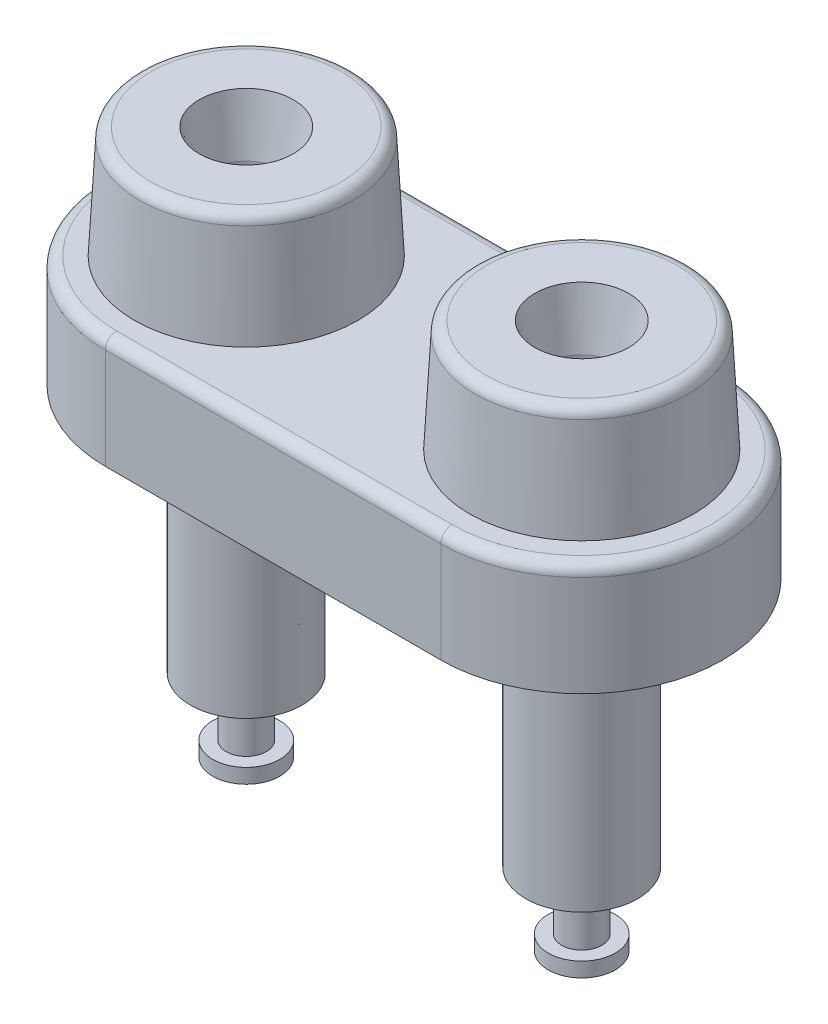
from build123d import *

# Parameters (mm, degrees)
BOSS_EXTRUDE1_DEPTH = 6.35
SKETCH2_R           = 6.35
BOSS_EXTRUDE2_DEPTH = 6.35
BOSS_EXTRUDE2_TAPER = 3
SKETCH3_R           = 4.699
BOSS_EXTRUDE3_DEPTH = 0.889
LPATTERN1_COUNT     = 2
LPATTERN1_PITCH     = 19.05
FILLET1_R           = 0.635
SKETCH5_R           = 2.1082
CUT_EXTRUDE1_DEPTH  = 25.4


with BuildPart() as part:
    # Sketch1 → Boss-Extrude1 (new body)
    with BuildSketch(Plane(origin=(0, 0, 0), x_dir=(1, 0, 0), z_dir=(0, 1, 0))):
        with BuildLine():
            Line((-9.525, 8.001), (9.525, 8.001))
            ThreePointArc((9.525, 8.001), (17.526, 0), (9.525, -8.001))
            Line((9.525, -8.001), (-9.525, -8.001))
            ThreePointArc((-9.525, -8.001), (-17.526, 0), (-9.525, 8.001))
        make_face()
    extrude(amount=BOSS_EXTRUDE1_DEPTH)

    # Sketch2 → Boss-Extrude2 (add)
    with BuildSketch(Plane(origin=(0, 6.35, 0), x_dir=(1, 0, 0), z_dir=(0, 1, 0))):
        with Locations((-9.525, 0)):
            Circle(SKETCH2_R)
        with Locations((9.525, 0)):
            Circle(SKETCH2_R)
    extrude(amount=BOSS_EXTRUDE2_DEPTH, taper=BOSS_EXTRUDE2_TAPER)

    # Sketch3 → Boss-Extrude3 (add)
    with BuildSketch(Plane.XZ):
        with Locations((-9.525, 0)):
            Circle(SKETCH3_R)
        with Locations((9.525, 0)):
            Circle(SKETCH3_R)
    extrude(amount=BOSS_EXTRUDE3_DEPTH)

    # Sketch4 → Revolve1 (revolve)
    with BuildSketch(Plane.XY):
        Polygon((9.525, -0.889), (9.525, -18.288), (7.62, -18.288), (7.62, -17.456876592), (8.382, -17.456876592), (8.382, -14.154876592), (6.35, -14.154876592), (6.35, -0.889), align=None)
    revolve1 = revolve(axis=Axis((9.525, -0.889, 0), (0, 1, 0)))

    # LPattern1: Revolve1 ×2
    with Locations(*[(-i * LPATTERN1_PITCH, 0, 0) for i in range(1, LPATTERN1_COUNT)]):
        add(revolve1)

    # Fillet1
    fillet1_edges = [part.edges().sort_by_distance(p)[0] for p in [
        (17.526, 6.35, 0),
        (0, 6.35, -8.001),
        (-15.542210602, 12.7, 0),
        (3.507789398, 12.7, 0),
        (-17.526, 6.35, 0),
        (0, 6.35, 8.001),
    ]]
    fillet(fillet1_edges, radius=FILLET1_R)

    # Sketch5 → Cut-Extrude1 (cut)
    with BuildSketch(Plane(origin=(0, 12.7, 0), x_dir=(1, 0, 0), z_dir=(0, 1, 0))):
        with Locations((-9.525, 0)):
            Circle(SKETCH5_R)
        with Locations((9.525, 0)):
            Circle(SKETCH5_R)
    extrude(amount=-CUT_EXTRUDE1_DEPTH, mode=Mode.SUBTRACT)

    # Sketch6 → flare (revolve, cut)
    with BuildSketch(Plane.XY):
        Polygon((6.409091305, 15.24), (7.4168, 9.525), (8.424508695, 15.24), align=None)
    flare = revolve(axis=Axis((9.525, -12.7, 0), (0, 1, 0)), mode=Mode.SUBTRACT)

    # Mirror1: flare across plane
    add(flare.mirror(Plane(origin=(0, 0, 0), x_dir=(0, 0, 1), z_dir=(1, 0, 0))), mode=Mode.SUBTRACT)


solid = part.part
